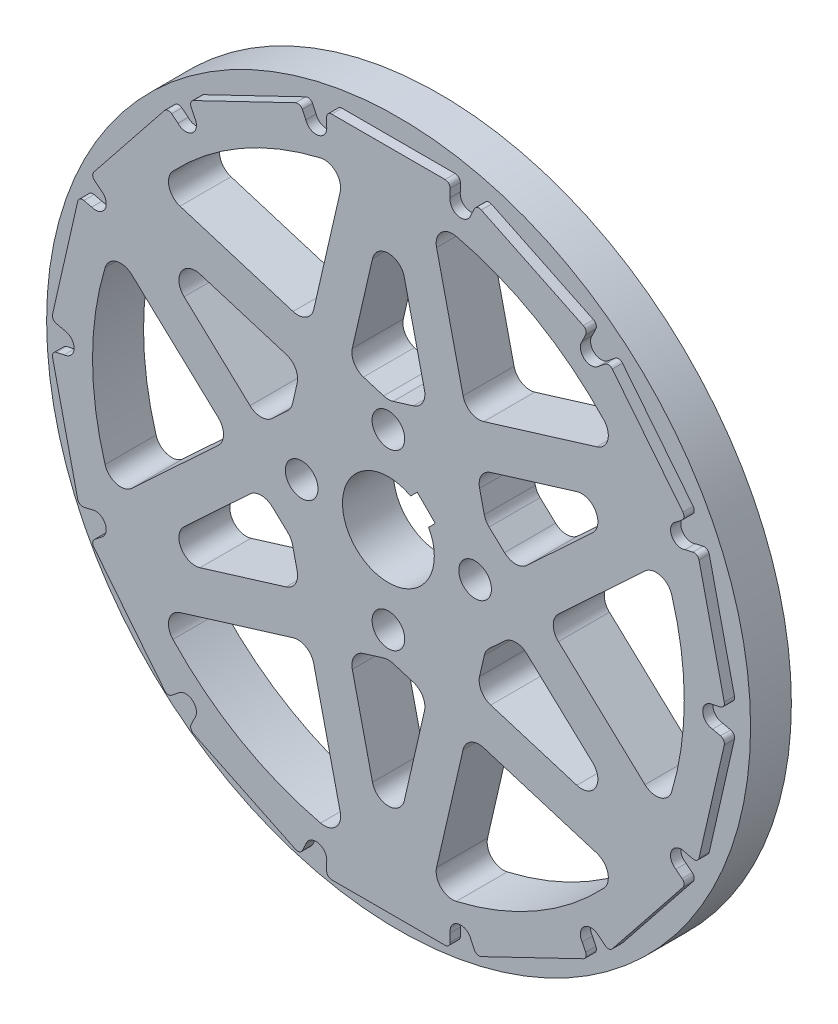
from build123d import *

# Parameters (mm, degrees)
SKETCH_1_R               = 34.5
EXTRUDE_1_DEPTH          = 4
SKETCH_2_R               = 31.5
EXTRUDE_2_DEPTH          = 1
SKETCH_3_W               = 12.1
SKETCH_3_H               = 2
EXTRUDE_3_DEPTH          = 1
PATTERN_CIRCULAR_1_COUNT = 14
SKETCH_5_R               = 1.05
CUT_EXTRUDE_1_DEPTH      = 1
PATTERN_CIRCULAR_2_COUNT = 14
SKETCH_6_R               = 4.5
CUT_EXTRUDE_2_DEPTH      = 6
SKETCH_7_R               = 29
SKETCH_7_R_2             = 10.5
CUT_EXTRUDE_3_DEPTH      = 1
CUT_EXTRUDE_3_DEPTH_BACK = 6
EXTRUDE_4_DEPTH          = 5
PATTERN_CIRCULAR_3_COUNT = 6
MIRROR_1_COPY_1_DEPTH    = 5
MIRROR_1_COPY_2_DEPTH    = 5
MIRROR_1_COPY_3_DEPTH    = 5
MIRROR_1_COPY_4_DEPTH    = 5
MIRROR_1_COPY_5_DEPTH    = 5
FILLET_1_R               = 0.5
FILLET_2_R               = 0.5
SKETCH_9_R               = 1.6
CUT_EXTRUDE_4_DEPTH      = 6
CUT_EXTRUDE_5_DEPTH      = 6
FILLET_3_R               = 1.6
FILLET_4_R               = 1.6


with BuildPart() as part:
    # ｽｹｯﾁ1 → ﾎﾞｽ - 押し出し1 (new body)
    with BuildSketch(Plane.XY):
        Circle(SKETCH_1_R)
    extrude(amount=EXTRUDE_1_DEPTH)

    # ｽｹｯﾁ2 → ﾎﾞｽ - 押し出し2 (add)
    with BuildSketch(Plane.XY.offset(4)):
        Circle(SKETCH_2_R)
    extrude(amount=EXTRUDE_2_DEPTH)

    # ｽｹｯﾁ3 → ﾎﾞｽ - 押し出し3 (add)
    with BuildSketch(Plane.XY.offset(4)):
        with Locations((0, 31.5)):
            Rectangle(SKETCH_3_W, SKETCH_3_H)
    extrude_3 = extrude(amount=EXTRUDE_3_DEPTH)

    # 円形ﾊﾟﾀｰﾝ1: ﾎﾞｽ - 押し出し3 ×14 about axis
    pattern_circular_1_axis = Axis((0, 0, 0), (0, 0, 1))
    for i in range(1, PATTERN_CIRCULAR_1_COUNT):
        add(extrude_3.rotate(pattern_circular_1_axis, i * 360 / PATTERN_CIRCULAR_1_COUNT))

    # ｽｹｯﾁ5 → ｶｯﾄ - 押し出し1 (cut)
    with BuildSketch(Plane.XY.offset(5)):
        with Locations((-7.089547386, 31.061336605)):
            Circle(SKETCH_5_R)
    cut_extrude_1 = extrude(amount=-CUT_EXTRUDE_1_DEPTH, mode=Mode.SUBTRACT)

    # 円形ﾊﾟﾀｰﾝ2: ｶｯﾄ - 押し出し1 ×14 about axis
    pattern_circular_2_axis = Axis((0, 0, 0), (0, 0, 1))
    for i in range(1, PATTERN_CIRCULAR_2_COUNT):
        add(cut_extrude_1.rotate(pattern_circular_2_axis, i * 360 / PATTERN_CIRCULAR_2_COUNT), mode=Mode.SUBTRACT)

    # ｽｹｯﾁ6 → ｶｯﾄ - 押し出し2 (cut, through all)
    with BuildSketch(Plane.XY.offset(5)):
        Circle(SKETCH_6_R)
    extrude(amount=-CUT_EXTRUDE_2_DEPTH, mode=Mode.SUBTRACT)

    # ｽｹｯﾁ7 → ｶｯﾄ - 押し出し3 (cut, two sides)
    with BuildSketch(Plane.XY.offset(5)) as cut_extrude_3_sk:
        Circle(SKETCH_7_R)
        Circle(SKETCH_7_R_2, mode=Mode.SUBTRACT)
    extrude(amount=CUT_EXTRUDE_3_DEPTH, mode=Mode.SUBTRACT)
    extrude(cut_extrude_3_sk.sketch, amount=-CUT_EXTRUDE_3_DEPTH_BACK, mode=Mode.SUBTRACT)

    # ｽｹｯﾁ8 → ﾎﾞｽ - 押し出し4 (add)
    with BuildSketch(Plane.XY.offset(5)):
        with BuildLine():
            Line((-10.232853034, 2.353448276), (-4.173869521, 28.698062883))
            ThreePointArc((-4.173869521, 28.698062883), (-2.092388157, 28.924417225), (0, 29))
            Line((0, 29), (-4.486334578, 9.493303011))
            ThreePointArc((-4.486334578, 9.493303011), (-8.179731193, 6.583463952), (-10.232853034, 2.353448276))
        make_face()
    extrude_4 = extrude(amount=-EXTRUDE_4_DEPTH)

    # 円形ﾊﾟﾀｰﾝ3: ﾎﾞｽ - 押し出し4 ×6 about axis
    pattern_circular_3_axis = Axis((0, 0, 0), (0, 0, 1))
    for i in range(1, PATTERN_CIRCULAR_3_COUNT):
        add(extrude_4.rotate(pattern_circular_3_axis, i * 360 / PATTERN_CIRCULAR_3_COUNT))

    # ﾐﾗｰ1: ﾎﾞｽ - 押し出し4 across plane
    add(extrude_4.mirror(Plane(origin=(0, 0, 0), x_dir=(0, 0, 1), z_dir=(1, 0, 0))))

    # ﾐﾗｰ1 copy 1 sketch → ﾐﾗｰ1 copy 1 (add)
    with BuildSketch(Plane(origin=(0, 0, 5), x_dir=(-0.5, 0.866025404, 0), z_dir=(0, 0, 1))):
        with BuildLine():
            Line((-10.232853034, -2.353448276), (-4.173869521, -28.698062883))
            ThreePointArc((-4.173869521, -28.698062883), (-2.092388157, -28.924417225), (0, -29))
            Line((0, -29), (-4.486334578, -9.493303011))
            ThreePointArc((-4.486334578, -9.493303011), (-8.179731193, -6.583463952), (-10.232853034, -2.353448276))
        make_face()
    extrude(amount=-MIRROR_1_COPY_1_DEPTH)

    # ﾐﾗｰ1 copy 2 sketch → ﾐﾗｰ1 copy 2 (add)
    with BuildSketch(Plane(origin=(0, 0, 5), x_dir=(0.5, 0.866025404, 0), z_dir=(0, 0, 1))):
        with BuildLine():
            Line((-10.232853034, -2.353448276), (-4.173869521, -28.698062883))
            ThreePointArc((-4.173869521, -28.698062883), (-2.092388157, -28.924417225), (0, -29))
            Line((0, -29), (-4.486334578, -9.493303011))
            ThreePointArc((-4.486334578, -9.493303011), (-8.179731193, -6.583463952), (-10.232853034, -2.353448276))
        make_face()
    extrude(amount=-MIRROR_1_COPY_2_DEPTH)

    # ﾐﾗｰ1 copy 3 sketch → ﾐﾗｰ1 copy 3 (add)
    with BuildSketch(Plane.XY.offset(5)):
        with BuildLine():
            Line((-10.232853034, -2.353448276), (-4.173869521, -28.698062883))
            ThreePointArc((-4.173869521, -28.698062883), (-2.092388157, -28.924417225), (0, -29))
            Line((0, -29), (-4.486334578, -9.493303011))
            ThreePointArc((-4.486334578, -9.493303011), (-8.179731193, -6.583463952), (-10.232853034, -2.353448276))
        make_face()
    extrude(amount=-MIRROR_1_COPY_3_DEPTH)

    # ﾐﾗｰ1 copy 4 sketch → ﾐﾗｰ1 copy 4 (add)
    with BuildSketch(Plane(origin=(0, 0, 5), x_dir=(0.5, -0.866025404, 0), z_dir=(0, 0, 1))):
        with BuildLine():
            Line((-10.232853034, -2.353448276), (-4.173869521, -28.698062883))
            ThreePointArc((-4.173869521, -28.698062883), (-2.092388157, -28.924417225), (0, -29))
            Line((0, -29), (-4.486334578, -9.493303011))
            ThreePointArc((-4.486334578, -9.493303011), (-8.179731193, -6.583463952), (-10.232853034, -2.353448276))
        make_face()
    extrude(amount=-MIRROR_1_COPY_4_DEPTH)

    # ﾐﾗｰ1 copy 5 sketch → ﾐﾗｰ1 copy 5 (add)
    with BuildSketch(Plane(origin=(0, 0, 5), x_dir=(-0.5, -0.866025404, 0), z_dir=(0, 0, 1))):
        with BuildLine():
            Line((-10.232853034, -2.353448276), (-4.173869521, -28.698062883))
            ThreePointArc((-4.173869521, -28.698062883), (-2.092388157, -28.924417225), (0, -29))
            Line((0, -29), (-4.486334578, -9.493303011))
            ThreePointArc((-4.486334578, -9.493303011), (-8.179731193, -6.583463952), (-10.232853034, -2.353448276))
        make_face()
    extrude(amount=-MIRROR_1_COPY_5_DEPTH)

    # ﾌｨﾚｯﾄ1
    fillet_1_edges = [part.edges().sort_by_distance(p)[0] for p in [
        (-30.338905495, -13.130244222, 4.5),
        (-33.031408796, -1.333616485, 4.5),
    ]]
    fillet(fillet_1_edges, radius=FILLET_1_R)

    # ﾌｨﾚｯﾄ2
    fillet_2_edges = [part.edges().sort_by_distance(p)[0] for p in [
        (-21.637409879, -24.993499029, 4.5),
        (-29.181636481, -15.533338091, 4.5),
        (-8.650359871, -31.906484828, 4.5),
        (-19.552083172, -26.656491585, 4.5),
        (6.05, -32.5, 4.5),
        (-6.05, -32.5, 4.5),
        (19.552083172, -26.656491585, 4.5),
        (8.650359871, -31.906484828, 4.5),
        (29.181636481, -15.533338091, 4.5),
        (21.637409879, -24.993499029, 4.5),
        (33.031408796, -1.333616485, 4.5),
        (30.338905495, -13.130244222, 4.5),
        (30.338905495, 13.130244222, 4.5),
        (33.031408796, 1.333616485, 4.5),
        (21.637409879, 24.993499029, 4.5),
        (29.181636481, 15.533338091, 4.5),
        (8.650359871, 31.906484828, 4.5),
        (19.552083172, 26.656491585, 4.5),
        (-6.05, 32.5, 4.5),
        (6.05, 32.5, 4.5),
        (-19.552083172, 26.656491585, 4.5),
        (-8.650359871, 31.906484828, 4.5),
        (-29.181636481, 15.533338091, 4.5),
        (-21.637409879, 24.993499029, 4.5),
        (-33.031408796, 1.333616485, 4.5),
        (-30.338905495, 13.130244222, 4.5),
    ]]
    fillet(fillet_2_edges, radius=FILLET_2_R)

    # ｽｹｯﾁ9 → ｶｯﾄ - 押し出し4 (cut, through all)
    with BuildSketch(Plane.XY.offset(5)):
        with Locations((-8.5, 0)):
            Circle(SKETCH_9_R)
        with Locations((0, 8.5)):
            Circle(SKETCH_9_R)
        with Locations((8.5, 0)):
            Circle(SKETCH_9_R)
        with Locations((0, -8.5)):
            Circle(SKETCH_9_R)
    extrude(amount=-CUT_EXTRUDE_4_DEPTH, mode=Mode.SUBTRACT)

    # ｽｹｯﾁ10 → ｶｯﾄ - 押し出し5 (cut, through all)
    with BuildSketch(Plane.XY.offset(5)):
        Polygon((1.060660172, 2.828427125), (2.828427125, 1.060660172), (4.596194078, 2.828427125), (2.828427125, 4.596194078), align=None)
    extrude(amount=-CUT_EXTRUDE_5_DEPTH, mode=Mode.SUBTRACT)

    # ﾌｨﾚｯﾄ3
    fillet_3_edges = [part.edges().sort_by_distance(p)[0] for p in [
        (4.173869521, -28.698062883, 2.5),
        (26.940186256, -10.734354404, 2.5),
        (25.11473671, -14.5, 2.5),
        (22.766316736, 17.963708478, 2.5),
        (25.11473671, 14.5, 2.5),
        (8.603710016, 9.437003605, 2.5),
        (3.87082985, 12.169533243, 2.5),
        (9.511183791, 5.491284522, 2.5),
        (7.704862858, 13.345213935, 2.5),
        (4.173869521, 28.698062883, 2.5),
        (12.474539865, -2.732529638, 2.5),
        (12.474539865, 2.732529638, 2.5),
        (15.409725716, 0, 2.5),
        (9.511183791, -5.491284522, 2.5),
        (26.940186256, 10.734354404, 2.5),
        (8.603710016, -9.437003605, 2.5),
        (7.704862858, -13.345213935, 2.5),
        (22.766316736, -17.963708478, 2.5),
        (-3.87082985, 12.169533243, 2.5),
        (-7.704862858, 13.345213935, 2.5),
        (0, 10.982569044, 2.5),
        (-22.766316736, 17.963708478, 2.5),
        (-4.173869521, 28.698062883, 2.5),
        (0, 29, 2.5),
    ]]
    fillet(fillet_3_edges, radius=FILLET_3_R)

    # ﾌｨﾚｯﾄ4
    fillet_4_edges = [part.edges().sort_by_distance(p)[0] for p in [
        (-26.940186256, 10.734354404, 2.5),
        (-25.11473671, 14.5, 2.5),
        (-22.766316736, -17.963708478, 2.5),
        (-25.11473671, -14.5, 2.5),
        (0, -29, 2.5),
        (3.87082985, -12.169533243, 2.5),
        (0, -10.982569044, 2.5),
        (-8.603710016, -9.437003605, 2.5),
        (-3.87082985, -12.169533243, 2.5),
        (-7.704862858, -13.345213935, 2.5),
        (-9.511183791, -5.491284522, 2.5),
        (-4.173869521, -28.698062883, 2.5),
        (-12.474539865, 2.732529638, 2.5),
        (-12.474539865, -2.732529638, 2.5),
        (-15.409725716, 0, 2.5),
        (-9.511183791, 5.491284522, 2.5),
        (-26.940186256, -10.734354404, 2.5),
        (-8.603710016, 9.437003605, 2.5),
    ]]
    fillet(fillet_4_edges, radius=FILLET_4_R)


solid = part.part
